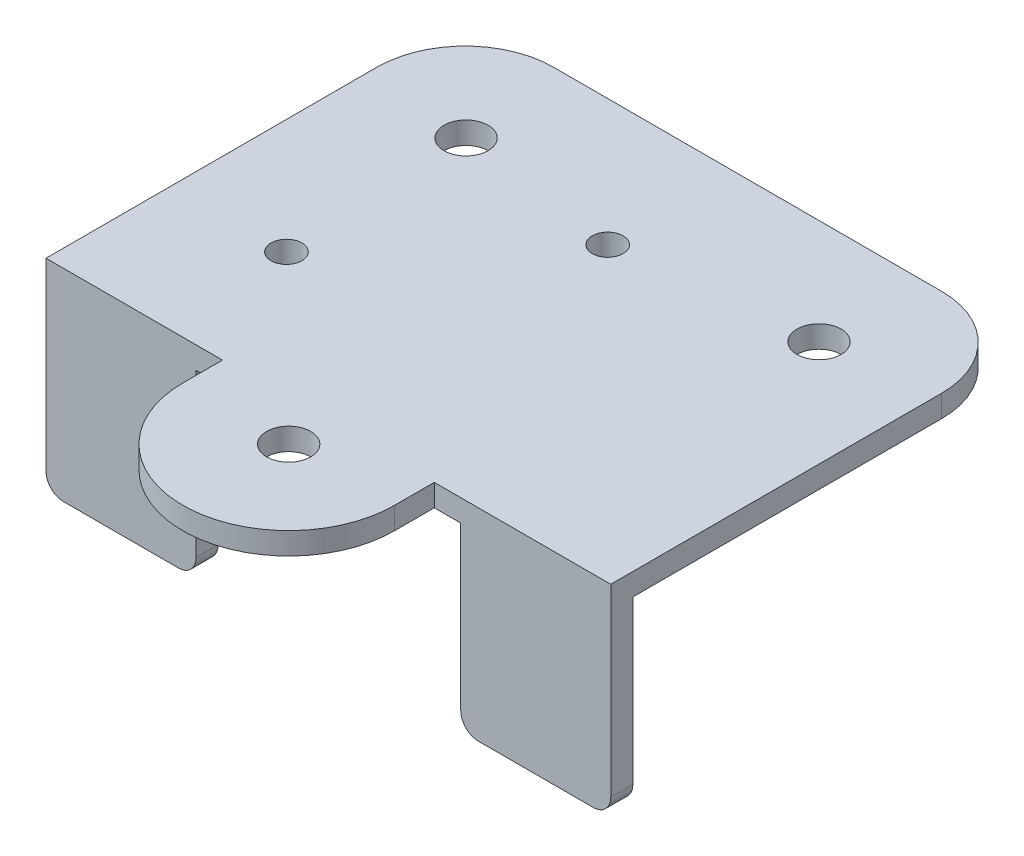
from build123d import *

# Parameters (mm, degrees)
SKETCH2_W           = 64
SKETCH2_H           = 47.5
SKETCH2_R           = 1.75
BOSS_EXTRUDE1_DEPTH = 2.5
FILLET1_R           = 10
SKETCH3_R           = 2.5
BOSS_EXTRUDE2_DEPTH = 2.5
SKETCH4_W           = 17
SKETCH4_H           = 2.5
BOSS_EXTRUDE3_DEPTH = 20.4
FILLET2_R           = 2
SKETCH5_R           = 2.5
CUT_EXTRUDE1_DEPTH  = 23.9


with BuildPart() as part:
    # Sketch2 → Boss-Extrude1 (new body)
    with BuildSketch(Plane(origin=(0, 0, 0), x_dir=(1, 0, 0), z_dir=(0, 1, 0))):
        Rectangle(SKETCH2_W, SKETCH2_H)
        with Locations((-1.5, 9.4)):
            Circle(SKETCH2_R, mode=Mode.SUBTRACT)
        with Locations((-19, -9.5)):
            Circle(SKETCH2_R, mode=Mode.SUBTRACT)
    extrude(amount=BOSS_EXTRUDE1_DEPTH)

    # Fillet1
    fillet1_edges = [part.edges().sort_by_distance(p)[0] for p in [
        (-32, 1.25, -23.75),
        (32, 1.25, -23.75),
    ]]
    fillet(fillet1_edges, radius=FILLET1_R)

    # Sketch3 → Boss-Extrude2 (add)
    with BuildSketch(Plane(origin=(0, 2.5, 0), x_dir=(1, 0, 0), z_dir=(0, 1, 0))):
        with BuildLine():
            Line((-12, -28.25), (-12, -23.75))
            Line((-12, -23.75), (12, -23.75))
            Line((12, -23.75), (12, -28.25))
            ThreePointArc((12, -28.25), (0, -40.25), (-12, -28.25))
        make_face()
        with Locations((0, -28.25)):
            Circle(SKETCH3_R, mode=Mode.SUBTRACT)
    extrude(amount=-BOSS_EXTRUDE2_DEPTH)

    # Sketch4 → Boss-Extrude3 (add)
    with BuildSketch(Plane.XZ):
        with Locations((-23.5, 22.5)):
            Rectangle(SKETCH4_W, SKETCH4_H)
        with Locations((23.5, 22.5)):
            Rectangle(SKETCH4_W, SKETCH4_H)
    extrude(amount=BOSS_EXTRUDE3_DEPTH)

    # Fillet2
    fillet2_edges = [part.edges().sort_by_distance(p)[0] for p in [
        (-32, -20.4, 22.5),
        (-15, -20.4, 22.5),
        (32, -20.4, 22.5),
        (15, -20.4, 22.5),
    ]]
    fillet(fillet2_edges, radius=FILLET2_R)

    # Sketch5 → Cut-Extrude1 (cut, through all)
    with BuildSketch(Plane(origin=(0, 2.5, 0), x_dir=(1, 0, 0), z_dir=(0, 1, 0))):
        with Locations((-20, 11.85)):
            Circle(SKETCH5_R)
        with Locations((20, 11.85)):
            Circle(SKETCH5_R)
    extrude(amount=-CUT_EXTRUDE1_DEPTH, mode=Mode.SUBTRACT)


solid = part.part
